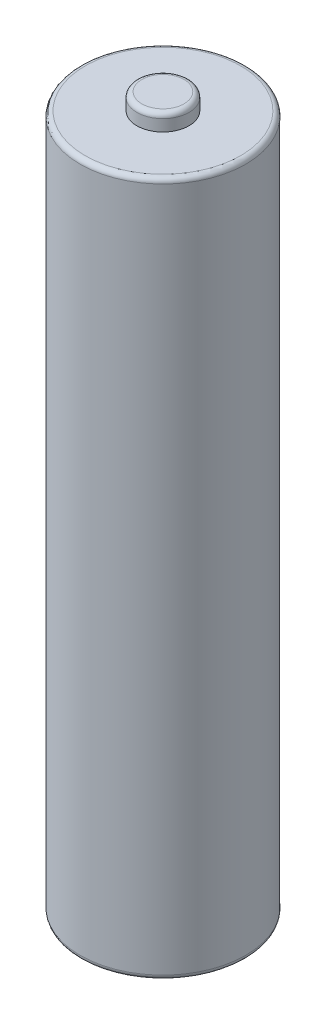
from build123d import *

# Parameters (mm, degrees)
SKETCH1_R           = 5
BOSS_EXTRUDE1_DEPTH = 42
SKETCH2_R           = 1.575
BOSS_EXTRUDE2_DEPTH = 1
FILLET1_R           = 0.3


with BuildPart() as part:
    # Sketch1 → Boss-Extrude1 (new body)
    with BuildSketch(Plane(origin=(0, 0, 0), x_dir=(1, 0, 0), z_dir=(0, 1, 0))):
        Circle(SKETCH1_R)
    extrude(amount=BOSS_EXTRUDE1_DEPTH)

    # Sketch2 → Boss-Extrude2 (add)
    with BuildSketch(Plane(origin=(0, 42, 0), x_dir=(1, 0, 0), z_dir=(0, 1, 0))):
        Circle(SKETCH2_R)
    extrude(amount=BOSS_EXTRUDE2_DEPTH)

    # Fillet1
    fillet1_edges = [part.edges().sort_by_distance(p)[0] for p in [
        (-5, 0, 0),
        (-5, 42, 0),
        (-1.575, 43, 0),
    ]]
    fillet(fillet1_edges, radius=FILLET1_R)


solid = part.part
